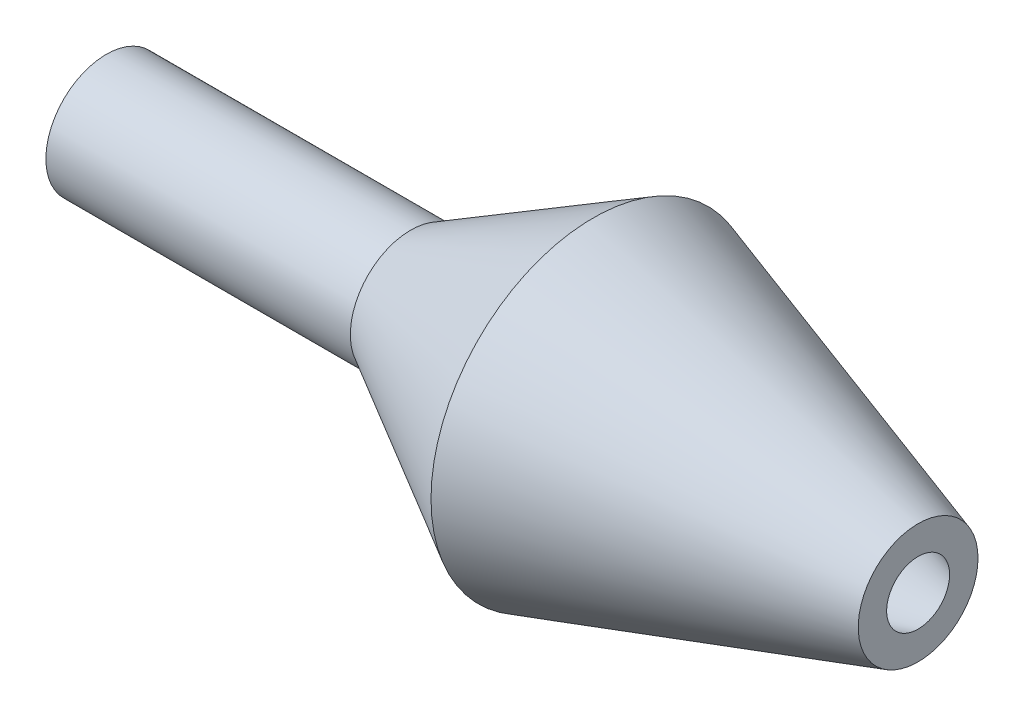
from build123d import *


with BuildPart() as part:
    # Sketch1 → Revolve1 (revolve)
    with BuildSketch(Plane(origin=(0, 0, 0), x_dir=(1, 0, 0), z_dir=(0, 1, 0))):
        Polygon((-40, 1.575), (-25, 1.575), (-16, 6.6), (0, 1.55), (0, 2.95), (-16, 8), (-25, 2.975), (-40, 2.975), align=None)
    revolve(axis=Axis((0, 0, 0), (-1, 0, 0)))


solid = part.part
